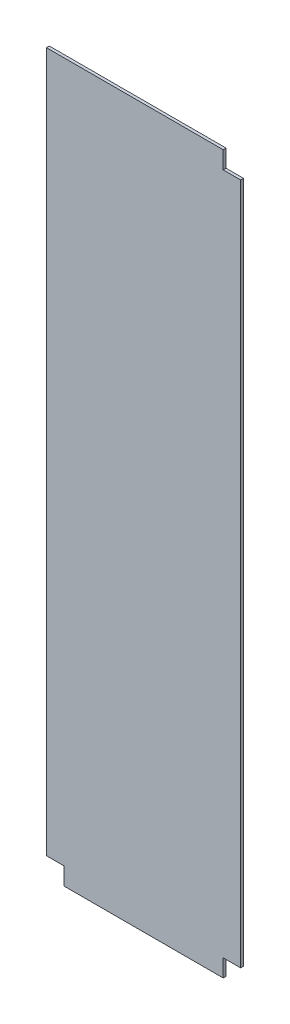
from build123d import *

# Parameters (mm, degrees)
SKETCH1_W           = 215.9
SKETCH1_H           = 797.2552
BOSS_EXTRUDE1_DEPTH = 3.175
SKETCH2_W           = 19.431
SKETCH2_H           = 19.431
CUT_EXTRUDE1_DEPTH  = 4.175


with BuildPart() as part:
    # Sketch1 → Boss-Extrude1 (new body)
    with BuildSketch(Plane.XY):
        with Locations((107.95, 398.6276)):
            Rectangle(SKETCH1_W, SKETCH1_H)
    extrude(amount=BOSS_EXTRUDE1_DEPTH)

    # Sketch2 → Cut-Extrude1 (cut, through all)
    with BuildSketch(Plane.XY.offset(3.175)):
        with Locations((206.1845, 787.5397)):
            Rectangle(SKETCH2_W, SKETCH2_H)
        with Locations((206.1845, 9.7155)):
            Rectangle(SKETCH2_W, SKETCH2_H)
        with Locations((9.7155, 9.7155)):
            Rectangle(SKETCH2_W, SKETCH2_H)
    extrude(amount=-CUT_EXTRUDE1_DEPTH, mode=Mode.SUBTRACT)


solid = part.part
